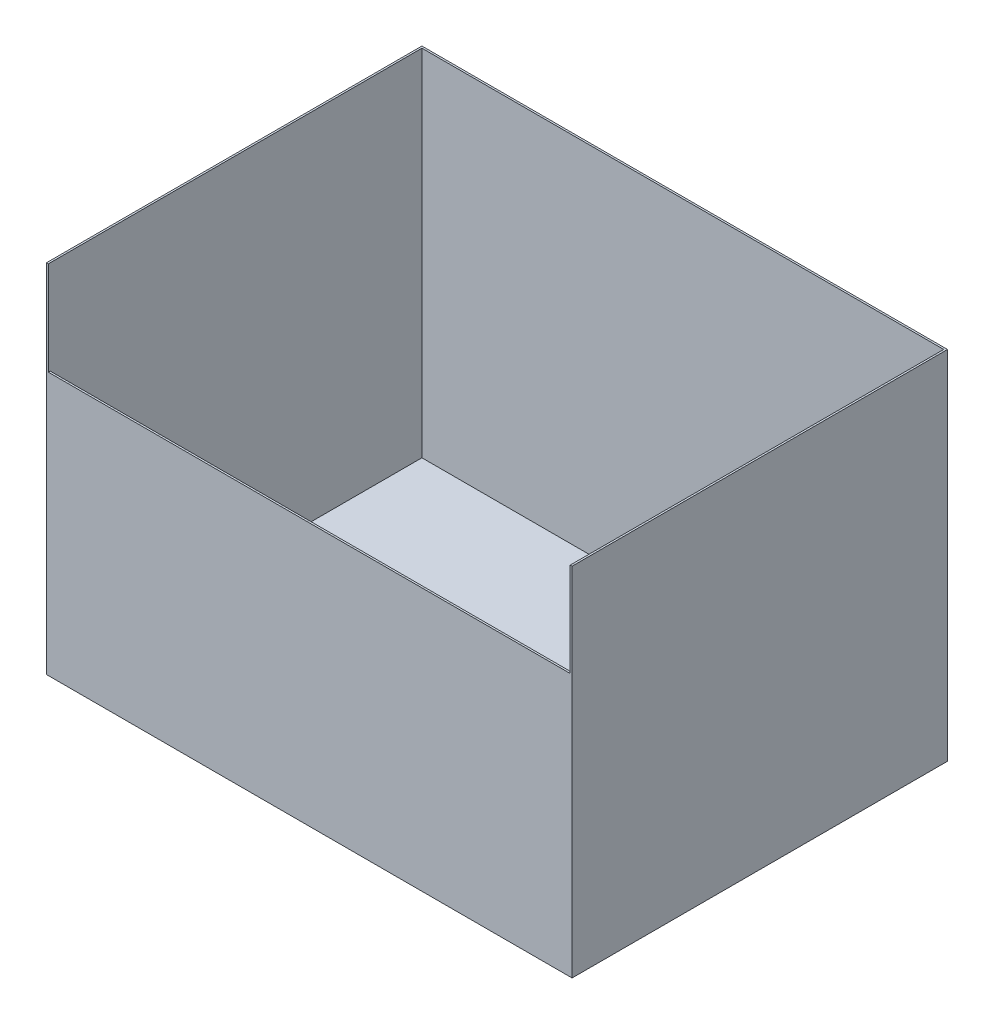
from build123d import *

# Parameters (mm, degrees)
SKETCH1_W           = 711.2
SKETCH1_H           = 508
BOSS_EXTRUDE1_DEPTH = 241.3
SHELL1_T            = -2.54
CUT_EXTRUDE1_REACH  = 510
SKETCH2_W           = 706.12
SKETCH2_H           = 127


with BuildPart() as part:
    # Sketch1 → Boss-Extrude1 (new body, symmetric)
    with BuildSketch(Plane(origin=(0, 0, 0), x_dir=(1, 0, 0), z_dir=(0, 1, 0))):
        Rectangle(SKETCH1_W, SKETCH1_H)
    extrude(amount=BOSS_EXTRUDE1_DEPTH, both=True)

    # Shell1
    shell1_openings = [part.faces().sort_by_distance(p)[0] for p in [
        (0, 241.3, 0),
    ]]
    offset(amount=SHELL1_T, openings=shell1_openings, kind=Kind.INTERSECTION)

    # Sketch2 → Cut-Extrude1 (cut, up to next)
    with BuildSketch(Plane.XY.offset(254), mode=Mode.PRIVATE) as cut_extrude1_sk1:
        with Locations((0, 177.8)):
            Rectangle(SKETCH2_W, SKETCH2_H)
    cut_extrude1_tool1 = extrude(cut_extrude1_sk1.sketch, amount=-CUT_EXTRUDE1_REACH, mode=Mode.PRIVATE) & part.part
    add(cut_extrude1_tool1.solids().sort_by_distance((0, 177.8, 254))[0], mode=Mode.SUBTRACT)


solid = part.part
